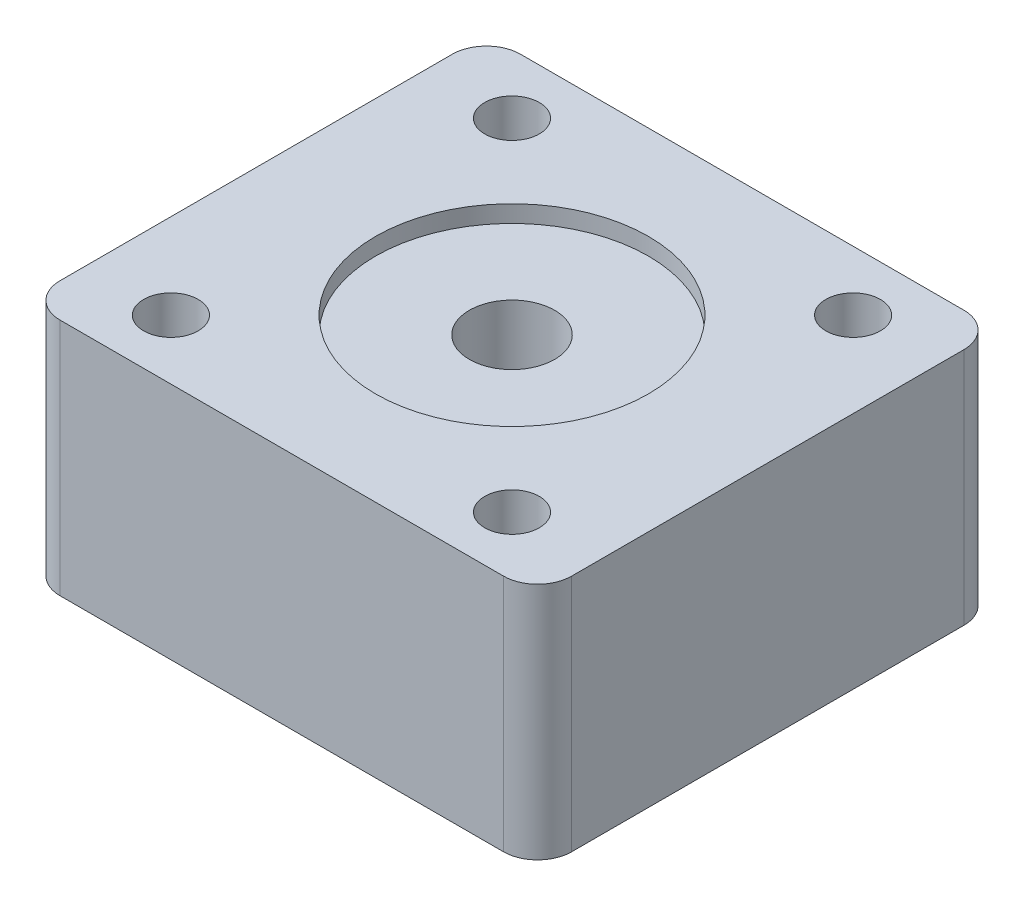
from build123d import *

# Parameters (mm, degrees)
SKETCH_1_W          = 30
SKETCH_1_H          = 27
SKETCH_1_R          = 1.6
EXTRUDE_1_DEPTH     = 14
SKETCH_2_R          = 2.5
CUT_EXTRUDE_1_DEPTH = 15
SKETCH_3_R          = 8
CUT_EXTRUDE_2_DEPTH = 1
FILLET_1_R          = 2


with BuildPart() as part:
    # 草图1 → 凸台-拉伸1 (new body)
    with BuildSketch(Plane(origin=(0, 0, 0), x_dir=(1, 0, 0), z_dir=(0, 1, 0))):
        Rectangle(SKETCH_1_W, SKETCH_1_H)
        with Locations((-10, 10)):
            Circle(SKETCH_1_R, mode=Mode.SUBTRACT)
        with Locations((10, 10)):
            Circle(SKETCH_1_R, mode=Mode.SUBTRACT)
        with Locations((10, -10)):
            Circle(SKETCH_1_R, mode=Mode.SUBTRACT)
        with Locations((-10, -10)):
            Circle(SKETCH_1_R, mode=Mode.SUBTRACT)
    extrude(amount=EXTRUDE_1_DEPTH)

    # 草图2 → 切除-拉伸1 (cut, through all)
    with BuildSketch(Plane(origin=(0, 14, 0), x_dir=(1, 0, 0), z_dir=(0, 1, 0))):
        Circle(SKETCH_2_R)
    extrude(amount=-CUT_EXTRUDE_1_DEPTH, mode=Mode.SUBTRACT)

    # 草图3 → 切除-拉伸2 (cut)
    with BuildSketch(Plane(origin=(0, 14, 0), x_dir=(1, 0, 0), z_dir=(0, 1, 0))):
        Circle(SKETCH_3_R)
    extrude(amount=-CUT_EXTRUDE_2_DEPTH, mode=Mode.SUBTRACT)

    # 圆角1
    fillet_1_edges = [part.edges().sort_by_distance(p)[0] for p in [
        (15, 7, 13.5),
        (-15, 7, 13.5),
        (-15, 7, -13.5),
        (15, 7, -13.5),
    ]]
    fillet(fillet_1_edges, radius=FILLET_1_R)


solid = part.part
